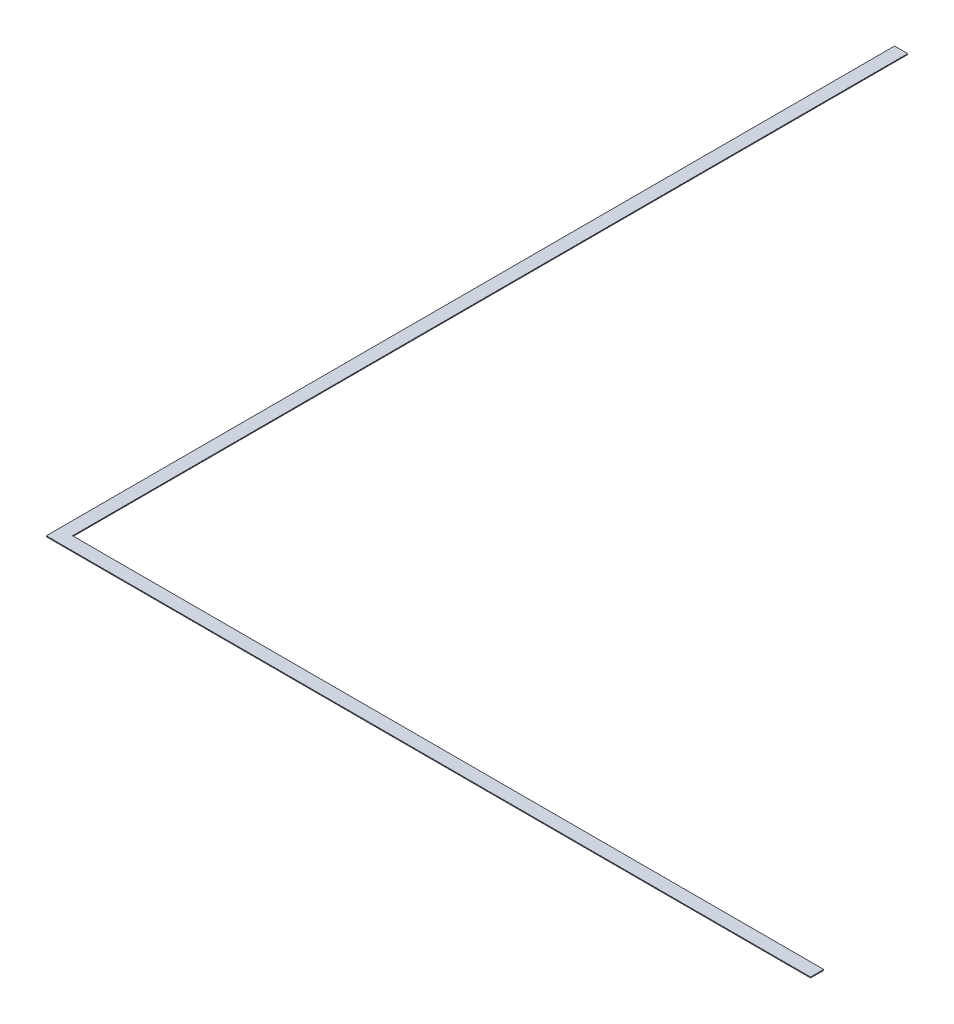
from build123d import *

# Parameters (mm, degrees)
BOSS_EXTRUDE1_DEPTH = 3.175


with BuildPart() as part:
    # Sketch1 → Boss-Extrude1 (new body)
    with BuildSketch(Plane(origin=(0, 0, 0), x_dir=(1, 0, 0), z_dir=(0, 1, 0))):
        Polygon((-1422.4, 1635.125), (-1473.2, 1635.125), (-1473.2, -1635.125), (1473.2, -1635.125), (1473.2, -1584.325), (-1422.4, -1584.325), align=None)
    extrude(amount=BOSS_EXTRUDE1_DEPTH)


solid = part.part
